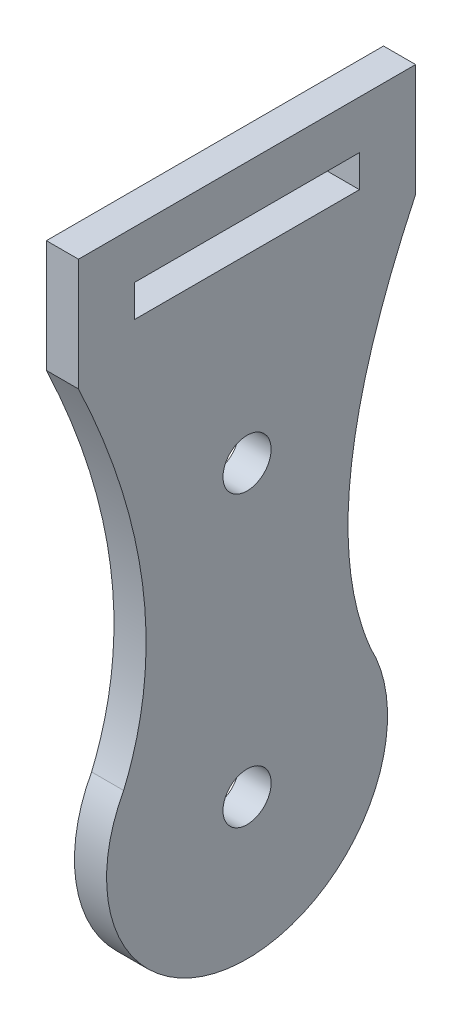
from build123d import *

# Parameters (mm, degrees)
RESSALTO_EXTRUS_O1_DEPTH = 2
ESBO_O2_R                = 1.5
ESBO_O2_W                = 14
ESBO_O2_H                = 2
CORTE_EXTRUS_O1_DEPTH    = 3.0000001


with BuildPart() as part:
    # Esboço1 → Ressalto-extrusão1 (new body)
    with BuildSketch(Plane(origin=(0, 0, 0), x_dir=(0, 0, -1), z_dir=(1, 0, 0))):
        with BuildLine():
            Line((-10.5, 34.25), (0, 34.25))
            Line((0, 34.25), (0, -8.75))
            ThreePointArc((0, -8.75), (-7.522394047, -4.46946169), (-7.684811888, 4.184037075))
            add(Edge.make_bspline(
                [(-10.5, 27.25), (-3.865048066, 13.251366251), (-7.684811888, 4.184037075)],
                knots=[0, 0, 0, 0.912495845, 0.912495845, 0.912495845], degree=2))
            Line((-10.5, 27.25), (-10.5, 34.25))
        make_face()
    ressalto_extrus_o1 = extrude(amount=RESSALTO_EXTRUS_O1_DEPTH)

    # Espelhar1: Ressalto-extrusão1 across plane
    add(ressalto_extrus_o1.mirror(Plane(origin=(2, 34.25, 0), x_dir=(1, 0, 0), z_dir=(0, 0, 1))))

    # Esboço2 → Corte-extrusão1 (cut, through all)
    with BuildSketch(Plane(origin=(2, 0, 0), x_dir=(0, 0, -1), z_dir=(1, 0, 0))):
        with Locations((0, 18)):
            Circle(ESBO_O2_R)
        Circle(ESBO_O2_R)
        with Locations((0, 30.25)):
            Rectangle(ESBO_O2_W, ESBO_O2_H)
    extrude(amount=-CORTE_EXTRUS_O1_DEPTH, mode=Mode.SUBTRACT)


solid = part.part
